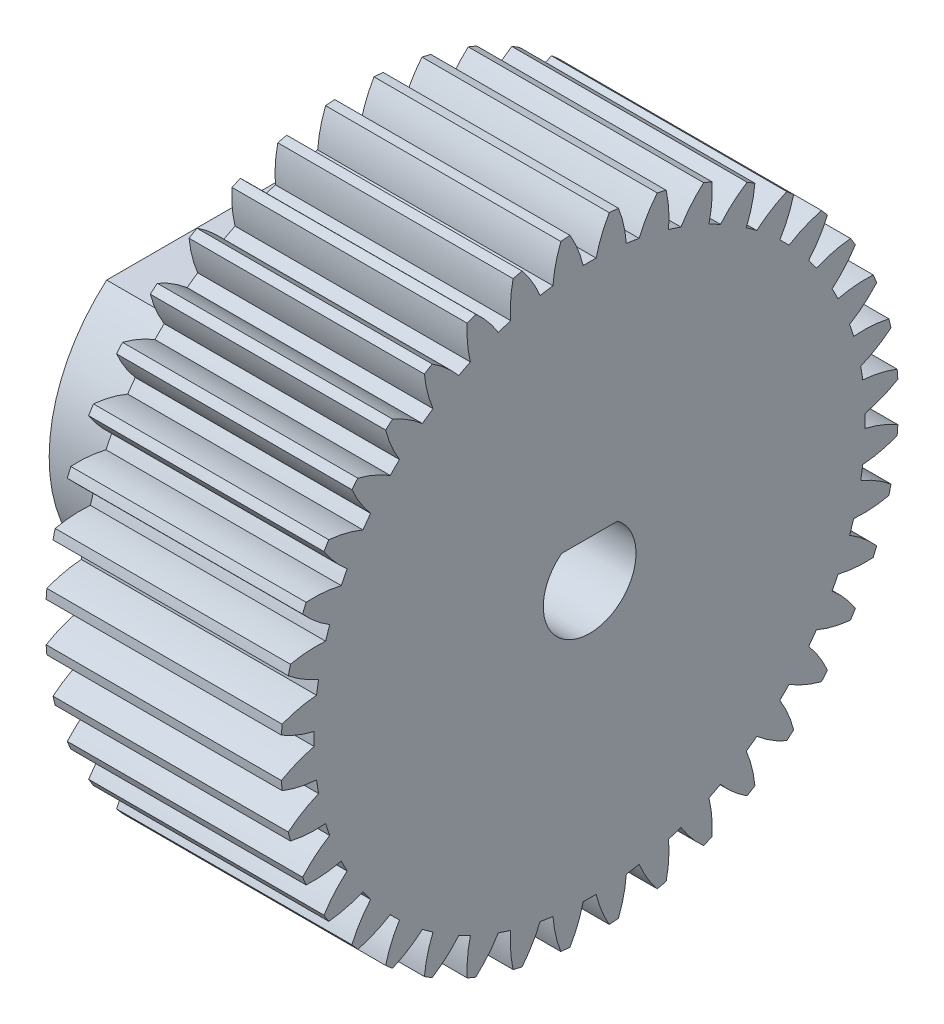
from build123d import *

# Parameters (mm, degrees)
BASPROSKE_W             = 12.7
BASPROSKE_H             = 16.66875
TOOTHCUT_DEPTH          = 27.776565372
TEETHCUTS_COUNT         = 40
TEETHCUTS_ANGLE         = 351
BORSKE_R                = 2.38125
BORE_DEPTH              = 50.8000508
SKETCH1_R               = 2.413
CUT_EXTRUDE1_DEPTH      = 12.7
SKETCH2_R               = 5.461
CUT_EXTRUDE2_DEPTH      = 12.7
CUT_EXTRUDE3_DEPTH      = 12.7
SKETCH4_R               = 5.461
SKETCH4_R_2             = 2.5019
BOSS_EXTRUDE1_DEPTH     = 12.7
BOSS_EXTRUDE2_DEPTH     = 12.7
SKETCH6_R               = 2.5019
BOSS_EXTRUDE3_DEPTH     = 7.62
CUT_EXTRUDE4_REACH      = 33.368
CUT_EXTRUDE4_END_RADIUS = 2.5019
SKETCH8_R               = 1.7526


with BuildPart() as part:
    # BasProSke → Base-Revolve (revolve)
    with BuildSketch(Plane(origin=(0, 0, 0), x_dir=(1, 0, 0), z_dir=(0, 1, 0)), mode=Mode.PRIVATE) as base_revolve_sk:
        with Locations((6.35, 8.334375)):
            Rectangle(BASPROSKE_W, BASPROSKE_H)
    revolve(base_revolve_sk.sketch.rotate(Axis((-10, 0, 0), (1, 0, 0)), 180), axis=Axis((-10, 0, 0), (1, 0, 0)))

    # TooCutSke → ToothCut (cut, through all)
    with BuildSketch(Plane(origin=(0, 0, 0), x_dir=(0, 0, -1), z_dir=(1, 0, 0))):
        with BuildLine():
            ThreePointArc((0.350893896, 14.867559799), (0, 14.8717), (-0.350893896, 14.867559799))
            ThreePointArc((-0.350893896, 14.867559799), (-0.644463151, 15.791243455), (-1.075185377, 16.659490407))
            ThreePointArc((-1.075185377, 16.659490407), (0, 16.69415), (1.075185377, 16.659490407))
            ThreePointArc((1.075185377, 16.659490407), (0.644463151, 15.791243455), (0.350893896, 14.867559799))
        make_face()
    toothcut = extrude(amount=TOOTHCUT_DEPTH, mode=Mode.SUBTRACT)

    # TeethCuts: ToothCut ×40 about axis
    teethcuts_axis = Axis((-10, 0, 0), (1, 0, 0))
    for i in range(1, TEETHCUTS_COUNT):
        add(toothcut.rotate(teethcuts_axis, i * TEETHCUTS_ANGLE / (TEETHCUTS_COUNT - 1)), mode=Mode.SUBTRACT)

    # BorSke → Bore (cut, symmetric)
    with BuildSketch(Plane(origin=(0, 0, 0), x_dir=(0, 0, -1), z_dir=(1, 0, 0))):
        with Locations(Location((0, 0, 0), (0, 0, 180))):
            Circle(BORSKE_R)
    extrude(amount=BORE_DEPTH, both=True, mode=Mode.SUBTRACT)

    # Sketch1 → Cut-Extrude1 (cut)
    with BuildSketch(Plane(origin=(12.7, 0, 0), x_dir=(0, 0, -1), z_dir=(1, 0, 0))):
        with Locations((-20.32, 20.32)):
            Circle(SKETCH1_R)
        with Locations((20.32, 20.32)):
            Circle(SKETCH1_R)
        with Locations((20.32, -20.32)):
            Circle(SKETCH1_R)
        with Locations((-20.32, -20.32)):
            Circle(SKETCH1_R)
    extrude(amount=-CUT_EXTRUDE1_DEPTH, mode=Mode.SUBTRACT)

    # Sketch2 → Cut-Extrude2 (cut)
    with BuildSketch(Plane(origin=(12.7, 0, 0), x_dir=(0, 0, -1), z_dir=(1, 0, 0))):
        Circle(SKETCH2_R)
    extrude(amount=-CUT_EXTRUDE2_DEPTH, mode=Mode.SUBTRACT)

    # Sketch3 → Cut-Extrude3 (cut)
    with BuildSketch(Plane(origin=(12.7, 0, 0), x_dir=(0, 0, -1), z_dir=(1, 0, 0))):
        with BuildLine():
            Line((19.793952373, -28.774208494), (6.771055825, -15.751311946))
            ThreePointArc((6.771055825, -15.751311946), (0, -17.145), (-6.771055825, -15.751311946))
            Line((-6.771055825, -15.751311946), (-19.793952373, -28.774208494))
            ThreePointArc((-19.793952373, -28.774208494), (0, -34.925), (19.793952373, -28.774208494))
        make_face()
        with BuildLine():
            Line((28.774208494, -19.793952373), (15.751311946, -6.771055825))
            ThreePointArc((15.751311946, -6.771055825), (17.145, 0), (15.751311946, 6.771055825))
            Line((15.751311946, 6.771055825), (28.774208494, 19.793952373))
            ThreePointArc((28.774208494, 19.793952373), (34.925, 0), (28.774208494, -19.793952373))
        make_face()
        with BuildLine():
            Line((-28.774208494, -19.793952373), (-15.751311946, -6.771055825))
            ThreePointArc((-15.751311946, -6.771055825), (-17.145, 0), (-15.751311946, 6.771055825))
            Line((-15.751311946, 6.771055825), (-28.774208494, 19.793952373))
            ThreePointArc((-28.774208494, 19.793952373), (-34.925, 0), (-28.774208494, -19.793952373))
        make_face()
        with BuildLine():
            Line((-6.771055825, 15.751311946), (-19.793952373, 28.774208494))
            ThreePointArc((-19.793952373, 28.774208494), (0, 34.925), (19.793952373, 28.774208494))
            Line((19.793952373, 28.774208494), (6.771055825, 15.751311946))
            ThreePointArc((6.771055825, 15.751311946), (0, 17.145), (-6.771055825, 15.751311946))
        make_face()
    extrude(amount=-CUT_EXTRUDE3_DEPTH, mode=Mode.SUBTRACT)

    # Sketch4 → Boss-Extrude1 (add)
    with BuildSketch(Plane(origin=(12.7, 0, 0), x_dir=(0, 0, -1), z_dir=(1, 0, 0))):
        Circle(SKETCH4_R)
        Circle(SKETCH4_R_2, mode=Mode.SUBTRACT)
    extrude(amount=-BOSS_EXTRUDE1_DEPTH)

    # Sketch5 → Boss-Extrude2 (add)
    with BuildSketch(Plane(origin=(12.7, 0, 0), x_dir=(0, 0, -1), z_dir=(1, 0, 0))):
        with BuildLine():
            Line((-1.511246638, 1.9939), (1.511246638, 1.9939))
            ThreePointArc((1.511246638, 1.9939), (0, 2.5019), (-1.511246638, 1.9939))
        make_face()
    extrude(amount=-BOSS_EXTRUDE2_DEPTH)

    # Sketch6 → Boss-Extrude3 (add)
    with BuildSketch(Plane.ZY):
        with BuildLine():
            Line((-5.748893164, 6.731), (5.748893164, 6.731))
            ThreePointArc((5.748893164, 6.731), (0, -8.8519), (-5.748893164, 6.731))
        make_face()
        with Locations(Location((0, 0, 0), (0, 0, 127.159762767))):
            Circle(SKETCH6_R, mode=Mode.SUBTRACT)
    extrude(amount=BOSS_EXTRUDE3_DEPTH)

    # Cut-Extrude4: up to this cylinder (the profile starts outside it)
    cut_extrude4_end = Plane(origin=(-3.81, 0, 0), z_dir=(1, 0, 0)) * Cylinder(CUT_EXTRUDE4_END_RADIUS, 72.7398, mode=Mode.PRIVATE)
    # Sketch8 → Cut-Extrude4 (cut, up to the surface)
    with BuildSketch(Plane(origin=(0, 6.731, 0), x_dir=(1, 0, 0), z_dir=(0, 1, 0)), mode=Mode.PRIVATE) as cut_extrude4_sk1:
        with Locations(Location((-3.81, 0, 0), (0, 0, 270))):
            Circle(SKETCH8_R)
    cut_extrude4_tool1 = extrude(cut_extrude4_sk1.sketch, amount=-CUT_EXTRUDE4_REACH, mode=Mode.PRIVATE) - cut_extrude4_end
    add(cut_extrude4_tool1.solids().sort_by_distance((-3.81, 6.731, 0))[0], mode=Mode.SUBTRACT)


solid = part.part
